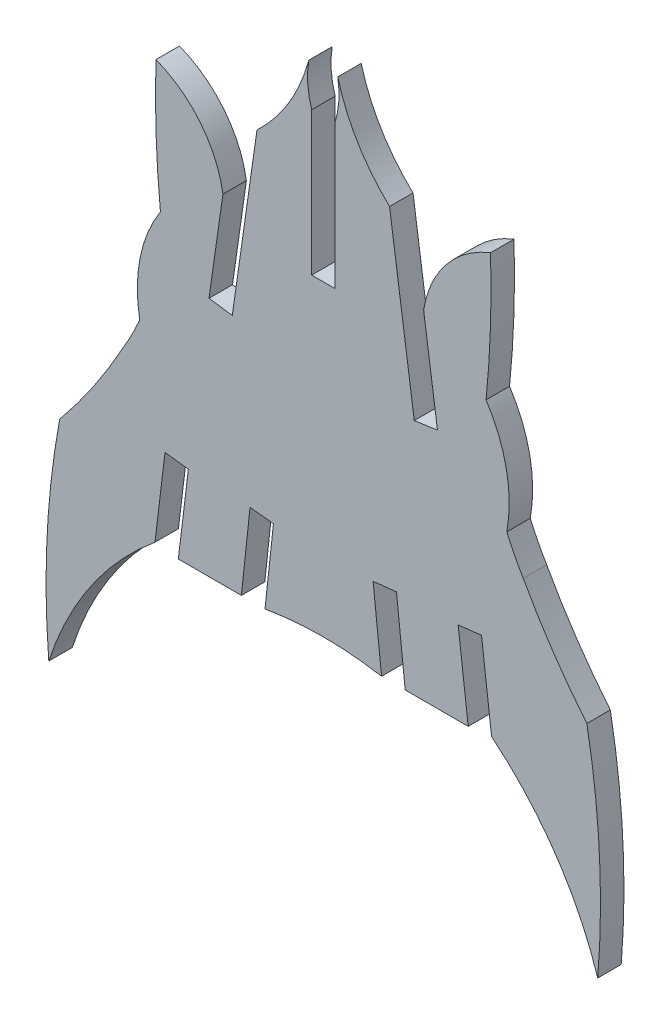
from build123d import *

# Parameters (mm, degrees)
BOSS_EXTRUDE1_DEPTH = 1.524


with BuildPart() as part:
    # Sketch1 → Boss-Extrude1 (new body)
    with BuildSketch(Plane.XY):
        with BuildLine():
            Line((-3.235155639, -8.287391484), (-3.783555133, -13.357106433))
            ThreePointArc((-3.783555133, -13.357106433), (0, -13.028347252), (3.783555133, -13.357106433))
            Line((3.783555133, -13.357106433), (3.235155639, -8.287391484))
            Line((3.235155639, -8.287391484), (4.755175848, -8.122474118))
            Line((4.755175848, -8.122474118), (5.317484152, -13.35909326))
            Line((5.317484152, -13.35909326), (9.410610808, -13.358099847))
            Line((9.410610808, -13.358099847), (8.758889671, -7.983387544))
            Line((8.758889671, -7.983387544), (10.274936224, -7.800587713))
            Line((10.274936224, -7.800587713), (10.926657362, -13.174306602))
            ThreePointArc((10.926657362, -13.174306602), (15.10168665, -17.742358652), (17.820275176, -23.301787175))
            ThreePointArc((17.820275176, -23.301787175), (17.932389495, -16.299261358), (17.11310908, -9.343924052))
            ThreePointArc((17.11310908, -9.343924052), (14.904545185, -6.389006387), (12.979613066, -3.241955511))
            ThreePointArc((12.979613066, -3.241955511), (12.412109671, -2.2224752), (11.916873155, -1.165999455))
            ThreePointArc((11.916873155, -1.165999455), (11.893308886, 2.337529648), (10.570541154, 5.581841128))
            ThreePointArc((10.570541154, 5.581841128), (10.855213093, 9.786127154), (10.861185965, 14.000035485))
            ThreePointArc((10.861185965, 14.000035485), (7.971038383, 11.880829677), (6.515279188, 8.605963044))
            Line((6.515279188, 8.605963044), (7.415708302, 2.300096505))
            Line((7.415708302, 2.300096505), (5.907609567, 2.085505398))
            Line((5.907609567, 2.085505398), (4.304137007, 13.321734283))
            ThreePointArc((4.304137007, 13.321734283), (2.229613922, 15.888650106), (0.940042002, 18.926693413))
            ThreePointArc((0.940042002, 18.926693413), (1.007296175, 17.568367421), (0.751408616, 16.232667535))
            Line((0.751408616, 16.232667535), (0.753449362, 6.933674836))
            Line((0.753449362, 6.933674836), (-0.753449362, 6.933674836))
            Line((-0.753449362, 6.933674836), (-0.751408616, 16.232667535))
            ThreePointArc((-0.751408616, 16.232667535), (-1.007296175, 17.568367421), (-0.940042002, 18.926693413))
            ThreePointArc((-0.940042002, 18.926693413), (-2.229613922, 15.888650106), (-4.304137007, 13.321734283))
            Line((-4.304137007, 13.321734283), (-5.907609567, 2.085505398))
            Line((-5.907609567, 2.085505398), (-7.415708302, 2.300096505))
            Line((-7.415708302, 2.300096505), (-6.515279188, 8.605963044))
            ThreePointArc((-6.515279188, 8.605963044), (-7.971038383, 11.880829677), (-10.861185965, 14.000035485))
            ThreePointArc((-10.861185965, 14.000035485), (-10.855213093, 9.786127154), (-10.570541154, 5.581841128))
            ThreePointArc((-10.570541154, 5.581841128), (-11.893308886, 2.337529648), (-11.916873155, -1.165999455))
            ThreePointArc((-11.916873155, -1.165999455), (-12.412109671, -2.2224752), (-12.979613066, -3.241955511))
            ThreePointArc((-12.979613066, -3.241955511), (-14.904545185, -6.389006387), (-17.11310908, -9.343924052))
            ThreePointArc((-17.11310908, -9.343924052), (-17.932389495, -16.299261358), (-17.820275176, -23.301787175))
            ThreePointArc((-17.820275176, -23.301787175), (-15.10168665, -17.742358652), (-10.926657362, -13.174306602))
            Line((-10.926657362, -13.174306602), (-10.274936224, -7.800587713))
            Line((-10.274936224, -7.800587713), (-8.758889671, -7.983387544))
            Line((-8.758889671, -7.983387544), (-9.410610808, -13.358099847))
            Line((-9.410610808, -13.358099847), (-5.317484152, -13.35909326))
            Line((-5.317484152, -13.35909326), (-4.755175848, -8.122474118))
            Line((-4.755175848, -8.122474118), (-3.235155639, -8.287391484))
        make_face()
    extrude(amount=BOSS_EXTRUDE1_DEPTH)


solid = part.part
